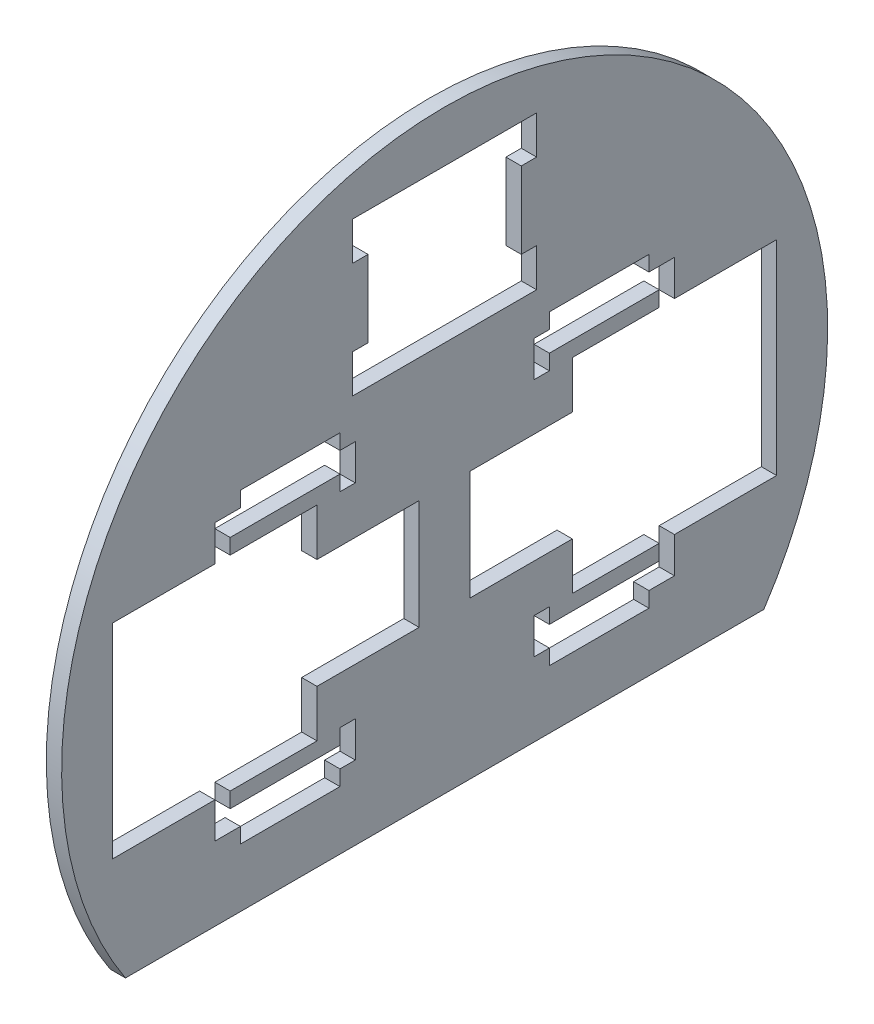
from build123d import *

# Parameters (mm, degrees)
BOSS_EXTRUDE1_DEPTH = 6
SKETCH2_W           = 80
SKETCH2_H           = 80
CUT_EXTRUDE1_DEPTH  = 6
SKETCH3_W           = 60
SKETCH3_H           = 60
CUT_EXTRUDE2_DEPTH  = 6
CUT_EXTRUDE3_DEPTH  = 10
SKETCH6_W           = 40
SKETCH6_H           = 43
CUT_EXTRUDE4_DEPTH  = 7
SKETCH7_W           = 6
SKETCH7_H           = 15
CUT_EXTRUDE5_DEPTH  = 7


with BuildPart() as part:
    # Sketch1 → Boss-Extrude1 (new body)
    with BuildSketch(Plane(origin=(0, 0, 0), x_dir=(0, 0, -1), z_dir=(1, 0, 0))):
        with BuildLine():
            Line((-125, -82.915619759), (125, -82.915619759))
            ThreePointArc((125, -82.915619759), (0, 150), (-125, -82.915619759))
        make_face()
    extrude(amount=BOSS_EXTRUDE1_DEPTH)

    # Sketch2 → Cut-Extrude1 (cut)
    with BuildSketch(Plane(origin=(6, 0, 0), x_dir=(0, 0, -1), z_dir=(1, 0, 0))):
        with Locations((-90, 0)):
            Rectangle(SKETCH2_W, SKETCH2_H)
        with Locations((90, 0)):
            Rectangle(SKETCH2_W, SKETCH2_H)
    extrude(amount=-CUT_EXTRUDE1_DEPTH, mode=Mode.SUBTRACT)

    # Sketch3 → Cut-Extrude2 (cut)
    with BuildSketch(Plane(origin=(6, 0, 0), x_dir=(0, 0, -1), z_dir=(1, 0, 0))):
        with Locations((0, 100)):
            Rectangle(SKETCH3_W, SKETCH3_H)
    extrude(amount=-CUT_EXTRUDE2_DEPTH, mode=Mode.SUBTRACT)

    # Sketch4 → Cut-Extrude3 (cut)
    with BuildSketch(Plane(origin=(6, 0, 0), x_dir=(0, 0, -1), z_dir=(1, 0, 0))):
        Polygon((-90, -40), (-84, -40), (-84, -46), (-41, -46), (-41, -40), (-35, -40), (-35, -54), (-41, -54), (-41, -60), (-80, -60), (-80, -54), (-90, -54), align=None)
        Polygon((-80, 60), (-41, 60), (-41, 54), (-35, 54), (-35, 40), (-41, 40), (-41, 46), (-84, 46), (-84, 40), (-90, 40), (-90, 54), (-80, 54), align=None)
        Polygon((80, -60), (41, -60), (41, -54), (35, -54), (35, -40), (41, -40), (41, -46), (84, -46), (84, -40), (90, -40), (90, -54), (80, -54), align=None)
        Polygon((90, 40), (90, 54), (80, 54), (80, 60), (41, 60), (41, 54), (35, 54), (35, 40), (41, 40), (41, 46), (84, 46), (84, 40), align=None)
    extrude(amount=-CUT_EXTRUDE3_DEPTH, mode=Mode.SUBTRACT)

    # Sketch6 → Cut-Extrude4 (cut, through all)
    with BuildSketch(Plane(origin=(6, 0, 0), x_dir=(0, 0, -1), z_dir=(1, 0, 0))):
        with Locations((-30, 0)):
            Rectangle(SKETCH6_W, SKETCH6_H)
        with Locations((30, 0)):
            Rectangle(SKETCH6_W, SKETCH6_H)
    extrude(amount=-CUT_EXTRUDE4_DEPTH, mode=Mode.SUBTRACT)

    # Sketch7 → Cut-Extrude5 (cut, through all)
    with BuildSketch(Plane(origin=(6, 0, 0), x_dir=(0, 0, -1), z_dir=(1, 0, 0))):
        with Locations((-33, 122.5)):
            Rectangle(SKETCH7_W, SKETCH7_H)
        with Locations((-33, 77.5)):
            Rectangle(SKETCH7_W, SKETCH7_H)
        with Locations((33, 77.5)):
            Rectangle(SKETCH7_W, SKETCH7_H)
        with Locations((33, 122.5)):
            Rectangle(SKETCH7_W, SKETCH7_H)
    extrude(amount=-CUT_EXTRUDE5_DEPTH, mode=Mode.SUBTRACT)


solid = part.part
